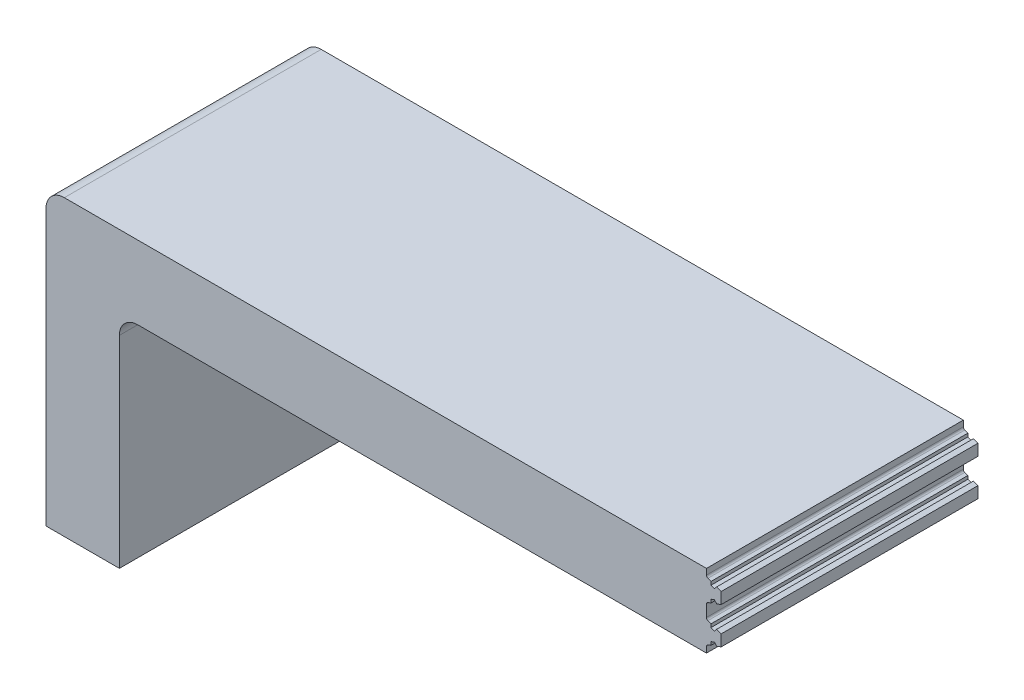
from build123d import *

# Parameters (mm, degrees)
BOSS_EXTRUDE2_DEPTH = 88.9
CUT_EXTRUDE3_DEPTH  = 89.9
FILLET2_R           = 6.35
FILLET4_R           = 0.762


with BuildPart() as part:
    # Sketch1 → Boss-Extrude2 (new body)
    with BuildSketch(Plane.XY):
        Polygon((0, 0), (0, 101.6), (233.68, 101.6), (233.68, 76.2), (25.4, 76.2), (25.4, 0), align=None)
    extrude(amount=BOSS_EXTRUDE2_DEPTH)

    # Sketch8 → Cut-Extrude3 (cut, through all)
    with BuildSketch(Plane.XY.offset(88.9)):
        Polygon((228.6, 76.2), (228.6, 78.740000094), (230.178469436, 79.314515955), (230.178469436, 80.449652208), (231.371879071, 80.88401777), (232.101530561, 80.014452928), (233.68, 80.58896879), (233.68, 76.2), align=None)
        Polygon((228.6, 101.6), (233.68, 101.6), (233.68, 97.21103121), (232.101530561, 97.785547072), (231.371879071, 96.91598223), (230.178469436, 97.350347792), (230.178469436, 98.485484045), (228.6, 99.059999906), align=None)
        Polygon((228.6, 86.36), (228.6, 91.44), (230.178469436, 92.014515861), (230.178469436, 93.149652114), (231.371879071, 93.584017676), (232.101530561, 92.714452834), (233.68, 93.288968696), (233.68, 84.511031304), (232.101530561, 85.085547166), (231.371879071, 84.215982324), (230.178469436, 84.650347886), (230.178469436, 85.785484139), align=None)
    extrude(amount=-CUT_EXTRUDE3_DEPTH, mode=Mode.SUBTRACT)

    # Fillet2
    fillet2_edges = [part.edges().sort_by_distance(p)[0] for p in [
        (0, 101.6, 44.45),
        (25.4, 76.2, 44.45),
    ]]
    fillet(fillet2_edges, radius=FILLET2_R)

    # Fillet4
    fillet4_edges = [part.edges().sort_by_distance(p)[0] for p in [
        (228.6, 78.740000094, 44.45),
        (228.6, 99.059999906, 44.45),
        (228.6, 91.44, 44.45),
        (228.6, 86.36, 44.45),
    ]]
    fillet(fillet4_edges, radius=FILLET4_R)


solid = part.part
